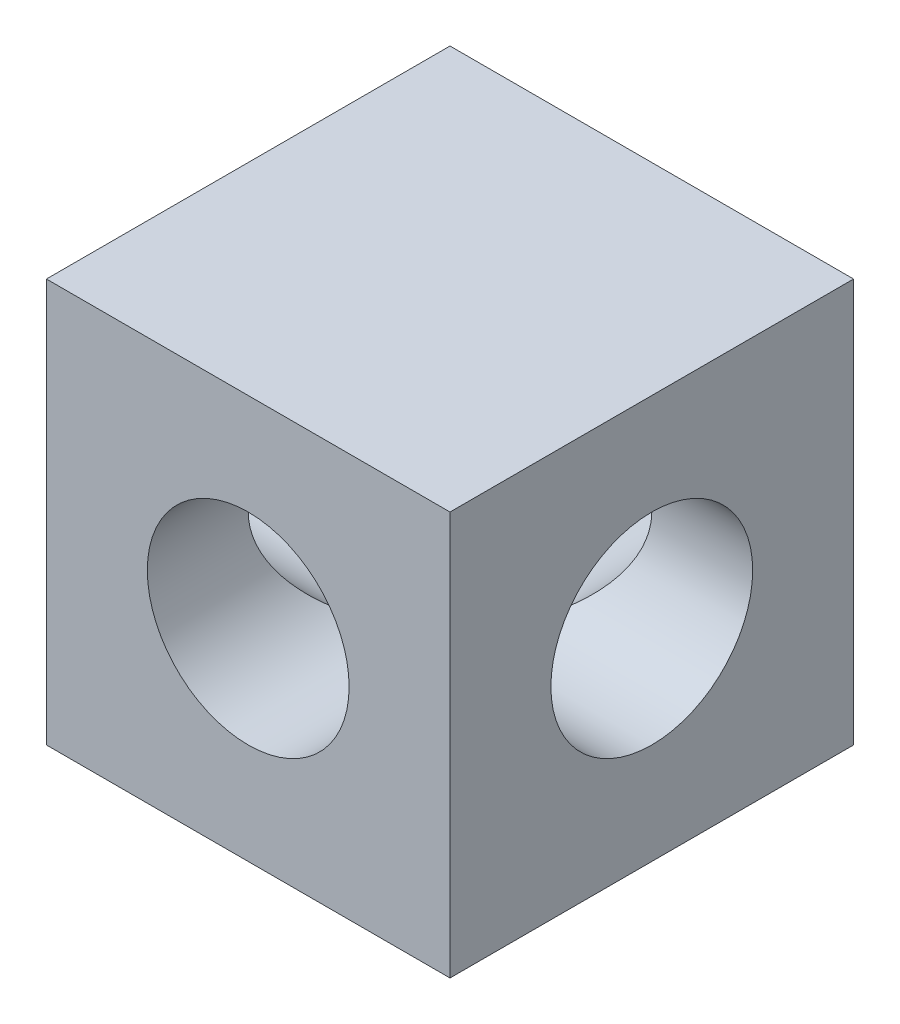
from build123d import *

# Parameters (mm, degrees)
SKETCH1_W           = 20
SKETCH1_H           = 20
BOSS_EXTRUDE1_DEPTH = 20
SKETCH2_R           = 5
CUT_EXTRUDE1_DEPTH  = 20
SKETCH3_R           = 5
CUT_EXTRUDE2_DEPTH  = 20


with BuildPart() as part:
    # Sketch1 → Boss-Extrude1 (new body)
    with BuildSketch(Plane.XY):
        Rectangle(SKETCH1_W, SKETCH1_H)
    extrude(amount=BOSS_EXTRUDE1_DEPTH)

    # Sketch2 → Cut-Extrude1 (cut)
    with BuildSketch(Plane.XY.offset(20)):
        Circle(SKETCH2_R)
    extrude(amount=-CUT_EXTRUDE1_DEPTH, mode=Mode.SUBTRACT)

    # Sketch3 → Cut-Extrude2 (cut)
    with BuildSketch(Plane(origin=(10, 0, 0), x_dir=(0, 0, -1), z_dir=(1, 0, 0))):
        with Locations((-10, 0)):
            Circle(SKETCH3_R)
    extrude(amount=-CUT_EXTRUDE2_DEPTH, mode=Mode.SUBTRACT)


solid = part.part
